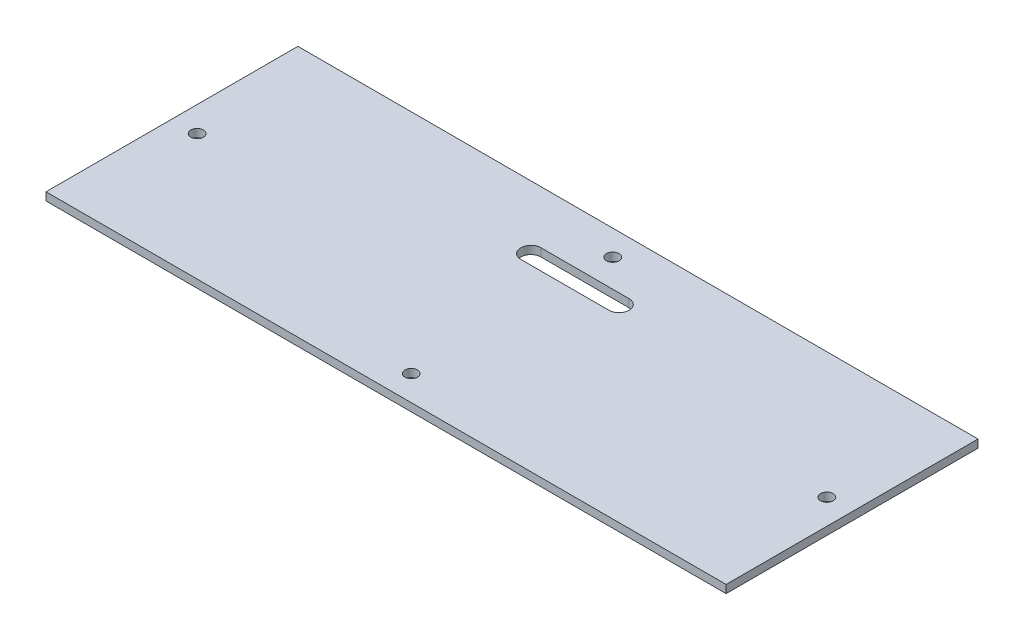
from build123d import *

# Parameters (mm, degrees)
SKETCH1_W               = 270
SKETCH1_H               = 100
BOSS_EXTRUDE1_DEPTH     = 3.175
SKETCH1_H_2             = 140
BOSS_EXTRUDE1_2_DEPTH   = 3.175
SKETCH2_R               = 2.5
CUT_EXTRUDE1_DEPTH      = 1
CUT_EXTRUDE1_DEPTH_BACK = 4.175


with BuildPart() as part:
    # Sketch1 → Boss-Extrude1 (new body)
    with BuildSketch(Plane(origin=(0, 0, 0), x_dir=(1, 0, 0), z_dir=(0, 1, 0))):
        with Locations((135, 50)):
            Rectangle(SKETCH1_W, SKETCH1_H)
    extrude(amount=BOSS_EXTRUDE1_DEPTH)


with BuildPart() as body_2:
    # Sketch1 → Boss-Extrude1 2 (new body)
    with BuildSketch(Plane(origin=(0, 0, 0), x_dir=(1, 0, 0), z_dir=(0, 1, 0))):
        with Locations((135, 175)):
            Rectangle(SKETCH1_W, SKETCH1_H_2)
    extrude(amount=BOSS_EXTRUDE1_2_DEPTH)


with BuildPart() as cut_extrude1_tool:
    # Sketch2 → Cut-Extrude1 (new body, two sides)
    with BuildSketch(Plane(origin=(0, 3.175, 0), x_dir=(1, 0, 0), z_dir=(0, 1, 0))) as cut_extrude1_sk:
        with Locations((10, 175)):
            Circle(SKETCH2_R)
        with Locations((10, 50)):
            Circle(SKETCH2_R)
        with Locations((260, 50)):
            Circle(SKETCH2_R)
        with Locations((260, 175)):
            Circle(SKETCH2_R)
        with Locations((135, 115)):
            Circle(SKETCH2_R)
        with Locations((135, 235)):
            Circle(SKETCH2_R)
        with Locations((135, 90)):
            Circle(SKETCH2_R)
        with Locations((135, 10)):
            Circle(SKETCH2_R)
        with BuildLine():
            Line((117.5, 79), (152.5, 79))
            ThreePointArc((152.5, 79), (156.5, 75), (152.5, 71))
            Line((152.5, 71), (117.5, 71))
            ThreePointArc((117.5, 71), (113.5, 75), (117.5, 79))
        make_face()
    extrude(amount=CUT_EXTRUDE1_DEPTH)
    extrude(cut_extrude1_sk.sketch, amount=-CUT_EXTRUDE1_DEPTH_BACK)


with BuildPart() as part_1:
    add(part.part)

    # Cut-Extrude1: cut by cut_extrude1_tool
    add(cut_extrude1_tool.part, mode=Mode.SUBTRACT)


with BuildPart() as body_2_1:
    add(body_2.part)

    # Cut-Extrude1: cut by cut_extrude1_tool
    add(cut_extrude1_tool.part, mode=Mode.SUBTRACT)


solid = part_1.part
